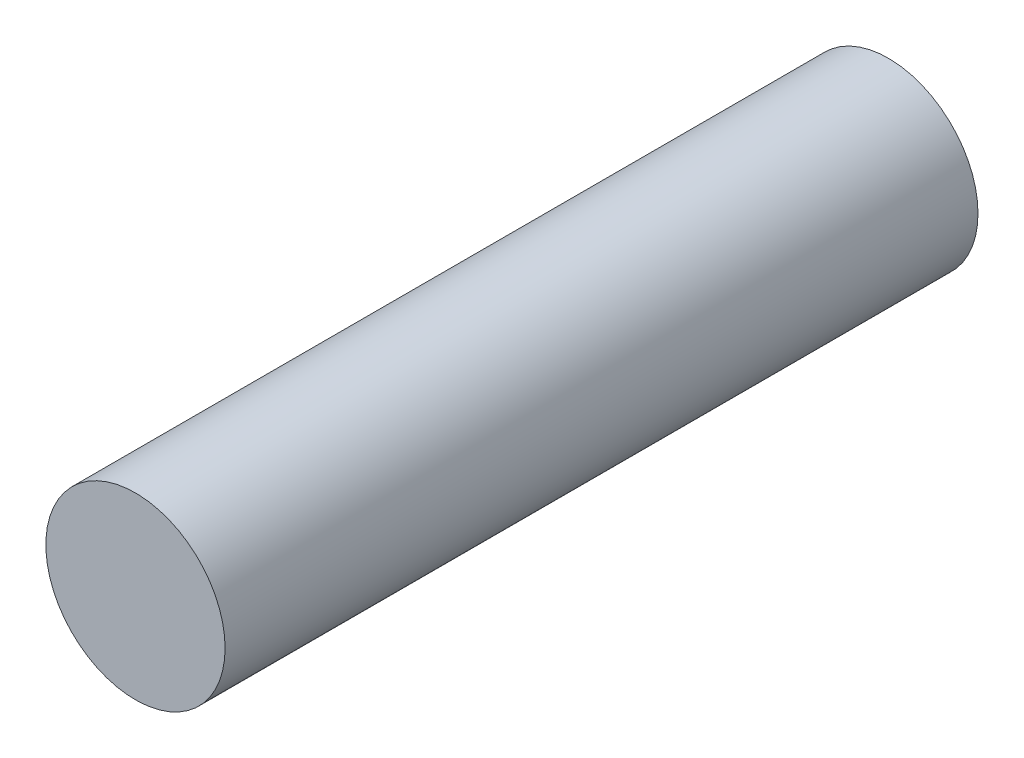
from build123d import *

# Parameters (mm, degrees)
SKETCH1_R           = 7.5
BOSS_EXTRUDE1_DEPTH = 63


with BuildPart() as part:
    # Sketch1 → Boss-Extrude1 (new body)
    with BuildSketch(Plane.XY):
        Circle(SKETCH1_R)
    extrude(amount=BOSS_EXTRUDE1_DEPTH)


solid = part.part
